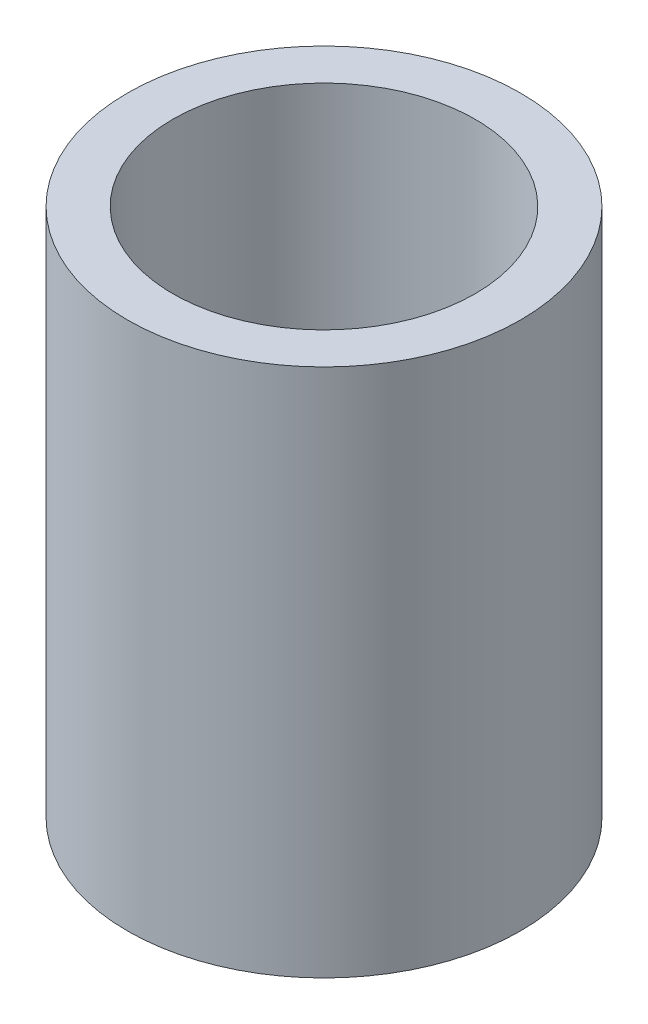
from build123d import *

# Parameters (mm, degrees)
SKETCH1_R           = 26
SKETCH1_R_2         = 20
EXTRUDE_THIN1_DEPTH = 70


with BuildPart() as part:
    # Sketch1 → Extrude-Thin1 (new body)
    with BuildSketch(Plane(origin=(0, 0, 0), x_dir=(1, 0, 0), z_dir=(0, 1, 0))):
        Circle(SKETCH1_R)
        Circle(SKETCH1_R_2, mode=Mode.SUBTRACT)
    extrude(amount=EXTRUDE_THIN1_DEPTH)


solid = part.part
